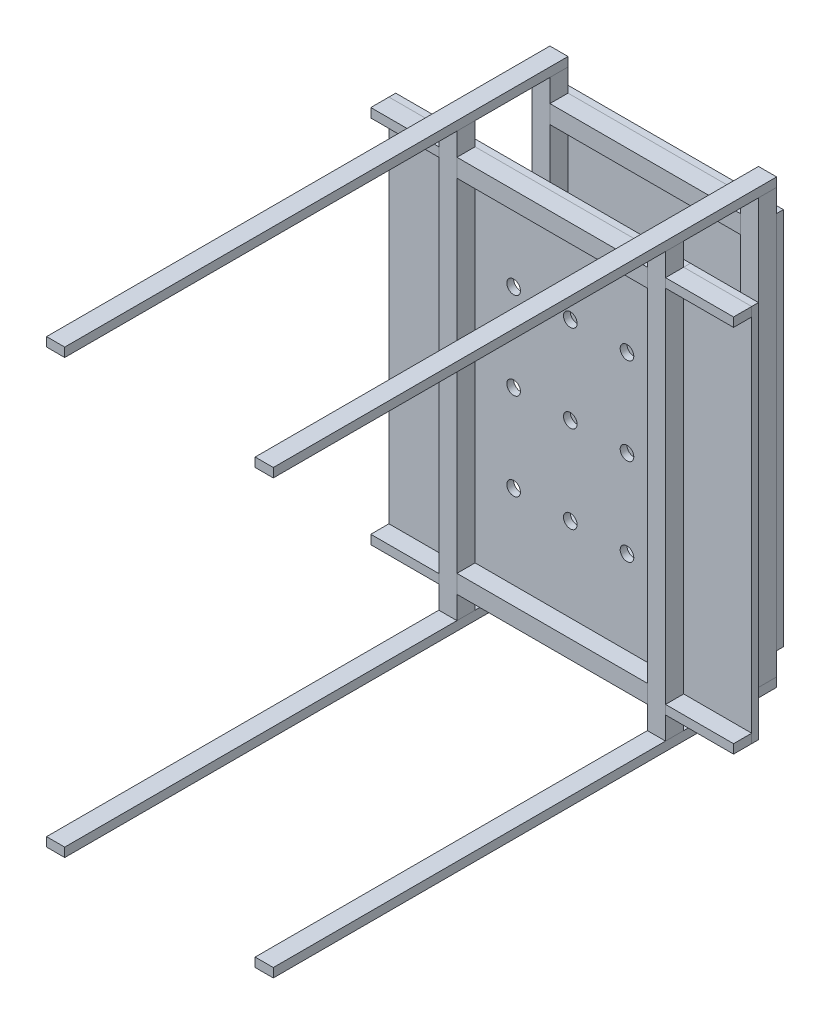
from build123d import *

# Parameters (mm, degrees)
SKETCH1_W               = 1000
SKETCH1_H               = 1950
BOSS_EXTRUDE1_DEPTH     = 30
SKETCH2_W               = 80
SKETCH2_H               = 40
BOSS_EXTRUDE2_DEPTH     = 2220
BOSS_EXTRUDE2_2_DEPTH   = 2220
BOSS_EXTRUDE2_3_DEPTH   = 2220
BOSS_EXTRUDE2_4_DEPTH   = 2220
SKETCH3_W               = 80
SKETCH3_H               = 80
BOSS_EXTRUDE3_DEPTH     = 1870
BOSS_EXTRUDE3_2_DEPTH   = 1870
SKETCH5_W               = 80
SKETCH5_H               = 80
BOSS_EXTRUDE5_DEPTH     = 1870
BOSS_EXTRUDE5_2_DEPTH   = 1870
SKETCH6_W               = 1000
SKETCH6_H               = 1670
BOSS_EXTRUDE6_DEPTH     = 30
SKETCH7_W               = 80
SKETCH7_H               = 40
BOSS_EXTRUDE7_DEPTH     = 300
BOSS_EXTRUDE7_2_DEPTH   = 300
SKETCH8_W               = 300
SKETCH8_H               = 1670
BOSS_EXTRUDE9_DEPTH     = 30
SKETCH9_W               = 1000
SKETCH9_H               = 140
CUT_EXTRUDE1_DEPTH      = 30
SKETCH11_W              = 80
SKETCH11_H              = 80
BOSS_EXTRUDE10_DEPTH    = 840
BOSS_EXTRUDE10_2_DEPTH  = 840
BOSS_EXTRUDE10_3_DEPTH  = 840
BOSS_EXTRUDE10_4_DEPTH  = 840
SKETCH12_W              = 30
SKETCH12_H              = 1670
BOSS_EXTRUDE11_DEPTH    = 300
SKETCH13_W              = 80
SKETCH13_H              = 40
BOSS_EXTRUDE12_DEPTH    = 300
BOSS_EXTRUDE12_2_DEPTH  = 300
SKETCH14_R              = 30
CUT_EXTRUDE2_DEPTH      = 1811
CUT_EXTRUDE2_DEPTH_BACK = 441


with BuildPart() as part:
    # Sketch1 → Boss-Extrude1 (new body)
    with BuildSketch(Plane.XY):
        with Locations((-500, -975)):
            Rectangle(SKETCH1_W, SKETCH1_H)
    extrude(amount=BOSS_EXTRUDE1_DEPTH)

    # Sketch9 → Cut-Extrude1 (cut)
    with BuildSketch(Plane(origin=(0, 0, 0), x_dir=(-1, 0, 0), z_dir=(0, 0, -1))):
        with Locations((500, -70)):
            Rectangle(SKETCH9_W, SKETCH9_H)
        with Locations((500, -1880)):
            Rectangle(SKETCH9_W, SKETCH9_H)
    extrude(amount=-CUT_EXTRUDE1_DEPTH, mode=Mode.SUBTRACT)


with BuildPart() as body_2:
    # Sketch2 → Boss-Extrude2 (new body)
    with BuildSketch(Plane.XY.offset(30)):
        with Locations((-40, -20)):
            Rectangle(SKETCH2_W, SKETCH2_H)
    extrude(amount=BOSS_EXTRUDE2_DEPTH)


with BuildPart() as body_3:
    # Sketch2 → Boss-Extrude2 2 (new body)
    with BuildSketch(Plane.XY.offset(30)):
        with Locations((-960, -20)):
            Rectangle(SKETCH2_W, SKETCH2_H)
    extrude(amount=BOSS_EXTRUDE2_2_DEPTH)


with BuildPart() as body_4:
    # Sketch2 → Boss-Extrude2 3 (new body)
    with BuildSketch(Plane.XY.offset(30)):
        with Locations((-40, -1930)):
            Rectangle(SKETCH2_W, SKETCH2_H)
    extrude(amount=BOSS_EXTRUDE2_3_DEPTH)


with BuildPart() as body_5:
    # Sketch2 → Boss-Extrude2 4 (new body)
    with BuildSketch(Plane.XY.offset(30)):
        with Locations((-960, -1930)):
            Rectangle(SKETCH2_W, SKETCH2_H)
    extrude(amount=BOSS_EXTRUDE2_4_DEPTH)


with BuildPart() as body_6:
    # Sketch3 → Boss-Extrude3 (new body)
    with BuildSketch(Plane(origin=(0, -1910, 0), x_dir=(1, 0, 0), z_dir=(0, 1, 0))):
        with Locations((-40, -70)):
            Rectangle(SKETCH3_W, SKETCH3_H)
    extrude(amount=BOSS_EXTRUDE3_DEPTH)


with BuildPart() as body_7:
    # Sketch3 → Boss-Extrude3 2 (new body)
    with BuildSketch(Plane(origin=(0, -1910, 0), x_dir=(1, 0, 0), z_dir=(0, 1, 0))):
        with Locations((-960, -70)):
            Rectangle(SKETCH3_W, SKETCH3_H)
    extrude(amount=BOSS_EXTRUDE3_2_DEPTH)


with BuildPart() as body_8:
    # Sketch5 → Boss-Extrude5 (new body)
    with BuildSketch(Plane(origin=(0, -1910, 0), x_dir=(1, 0, 0), z_dir=(0, 1, 0))):
        with Locations((-960, -480)):
            Rectangle(SKETCH5_W, SKETCH5_H)
    extrude(amount=BOSS_EXTRUDE5_DEPTH)


with BuildPart() as body_9:
    # Sketch5 → Boss-Extrude5 2 (new body)
    with BuildSketch(Plane(origin=(0, -1910, 0), x_dir=(1, 0, 0), z_dir=(0, 1, 0))):
        with Locations((-40, -480)):
            Rectangle(SKETCH5_W, SKETCH5_H)
    extrude(amount=BOSS_EXTRUDE5_2_DEPTH)


with BuildPart() as body_10:
    # Sketch6 → Boss-Extrude6 (new body)
    with BuildSketch(Plane(origin=(0, 0, 440), x_dir=(-1, 0, 0), z_dir=(0, 0, -1))):
        with Locations((500, -975)):
            Rectangle(SKETCH6_W, SKETCH6_H)
    extrude(amount=BOSS_EXTRUDE6_DEPTH)


with BuildPart() as body_11:
    # Sketch7 → Boss-Extrude7 (new body)
    with BuildSketch(Plane(origin=(0, 0, 0), x_dir=(0, 0, -1), z_dir=(1, 0, 0))):
        with Locations((-480, -160)):
            Rectangle(SKETCH7_W, SKETCH7_H)
    extrude(amount=BOSS_EXTRUDE7_DEPTH)


with BuildPart() as body_12:
    # Sketch7 → Boss-Extrude7 2 (new body)
    with BuildSketch(Plane(origin=(0, 0, 0), x_dir=(0, 0, -1), z_dir=(1, 0, 0))):
        with Locations((-480, -1790)):
            Rectangle(SKETCH7_W, SKETCH7_H)
    extrude(amount=BOSS_EXTRUDE7_2_DEPTH)


with BuildPart() as body_13:
    # Sketch8 → Boss-Extrude9 (new body)
    with BuildSketch(Plane(origin=(0, 0, 440), x_dir=(-1, 0, 0), z_dir=(0, 0, -1))):
        with Locations((-150, -975)):
            Rectangle(SKETCH8_W, SKETCH8_H)
    extrude(amount=BOSS_EXTRUDE9_DEPTH)


with BuildPart() as body_14:
    # Sketch11 → Boss-Extrude10 (new body)
    with BuildSketch(Plane(origin=(-920, 0, 0), x_dir=(0, 0, -1), z_dir=(1, 0, 0))):
        with Locations((-70, -179.992574532)):
            Rectangle(SKETCH11_W, SKETCH11_H)
    extrude(amount=BOSS_EXTRUDE10_DEPTH)


with BuildPart() as body_15:
    # Sketch11 → Boss-Extrude10 2 (new body)
    with BuildSketch(Plane(origin=(-920, 0, 0), x_dir=(0, 0, -1), z_dir=(1, 0, 0))):
        with Locations((-480, -179.992574532)):
            Rectangle(SKETCH11_W, SKETCH11_H)
    extrude(amount=BOSS_EXTRUDE10_2_DEPTH)


with BuildPart() as body_16:
    # Sketch11 → Boss-Extrude10 3 (new body)
    with BuildSketch(Plane(origin=(-920, 0, 0), x_dir=(0, 0, -1), z_dir=(1, 0, 0))):
        with Locations((-480, -1769.390680485)):
            Rectangle(SKETCH11_W, SKETCH11_H)
    extrude(amount=BOSS_EXTRUDE10_3_DEPTH)


with BuildPart() as body_17:
    # Sketch11 → Boss-Extrude10 4 (new body)
    with BuildSketch(Plane(origin=(-920, 0, 0), x_dir=(0, 0, -1), z_dir=(1, 0, 0))):
        with Locations((-70, -1769.390680485)):
            Rectangle(SKETCH11_W, SKETCH11_H)
    extrude(amount=BOSS_EXTRUDE10_4_DEPTH)


with BuildPart() as body_18:
    # Sketch12 → Boss-Extrude11 (new body)
    with BuildSketch(Plane.ZY.offset(1000)):
        with Locations((425, -975)):
            Rectangle(SKETCH12_W, SKETCH12_H)
    extrude(amount=BOSS_EXTRUDE11_DEPTH)


with BuildPart() as body_19:
    # Sketch13 → Boss-Extrude12 (new body)
    with BuildSketch(Plane.ZY.offset(1000)):
        with Locations((480, -160)):
            Rectangle(SKETCH13_W, SKETCH13_H)
    extrude(amount=BOSS_EXTRUDE12_DEPTH)


with BuildPart() as body_20:
    # Sketch13 → Boss-Extrude12 2 (new body)
    with BuildSketch(Plane.ZY.offset(1000)):
        with Locations((480, -1790)):
            Rectangle(SKETCH13_W, SKETCH13_H)
    extrude(amount=BOSS_EXTRUDE12_2_DEPTH)


with BuildPart() as cut_extrude2_tool:
    # Sketch14 → Cut-Extrude2 (new body, two sides)
    with BuildSketch(Plane.XY.offset(440)) as cut_extrude2_sk:
        with Locations((-750, -589.992574532)):
            Circle(SKETCH14_R)
        with Locations((-500, -589.992574532)):
            Circle(SKETCH14_R)
        with Locations((-250, -589.992574532)):
            Circle(SKETCH14_R)
        with Locations((-500, -974.691627509)):
            Circle(SKETCH14_R)
        with Locations((-250, -974.691627509)):
            Circle(SKETCH14_R)
        with Locations((-500, -1359.390680485)):
            Circle(SKETCH14_R)
        with Locations((-250, -1359.390680485)):
            Circle(SKETCH14_R)
        with Locations((-750, -974.691627509)):
            Circle(SKETCH14_R)
        with Locations((-750, -1359.390680485)):
            Circle(SKETCH14_R)
    extrude(amount=CUT_EXTRUDE2_DEPTH)
    extrude(cut_extrude2_sk.sketch, amount=-CUT_EXTRUDE2_DEPTH_BACK)


with BuildPart() as part_1:
    add(part.part)

    # Cut-Extrude2: cut by cut_extrude2_tool
    add(cut_extrude2_tool.part, mode=Mode.SUBTRACT)


with BuildPart() as body_10_1:
    add(body_10.part)

    # Cut-Extrude2: cut by cut_extrude2_tool
    add(cut_extrude2_tool.part, mode=Mode.SUBTRACT)


solid = Compound([body_2.part, body_3.part, body_4.part, body_5.part, body_6.part, body_7.part, body_8.part, body_9.part, body_11.part, body_12.part, body_13.part, body_14.part, body_15.part, body_16.part, body_17.part, body_18.part, body_19.part, body_20.part, part_1.part, body_10_1.part])
